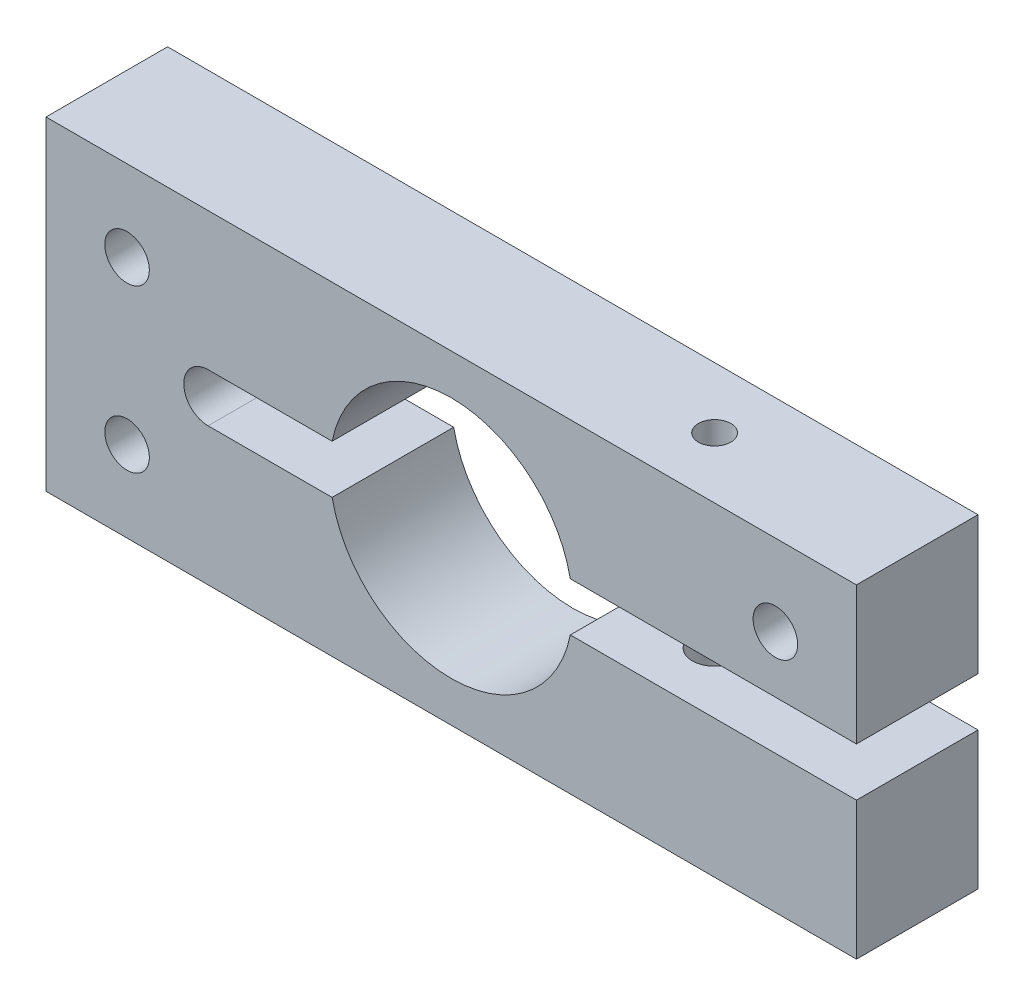
from build123d import *

# Parameters (mm, degrees)
SKETCH1_R           = 2.75
BOSS_EXTRUDE1_DEPTH = 15
SKETCH2_R           = 2
CUT_EXTRUDE1_DEPTH  = 41
SKETCH3_R           = 4.5
CUT_EXTRUDE2_DEPTH  = 5
SKETCH4_R           = 4.5
CUT_EXTRUDE3_DEPTH  = 5
CUT_EXTRUDE4_REACH  = 37
SKETCH5_R           = 2.75


with BuildPart() as part:
    # Sketch1 → Boss-Extrude1 (new body)
    with BuildSketch(Plane.XY):
        with BuildLine():
            Line((0, 0), (100, 0))
            Line((100, 0), (100, 17))
            Line((100, 17), (64.696938457, 17))
            ThreePointArc((64.696938457, 17), (50, 5), (35.303061543, 17))
            Line((35.303061543, 17), (20, 17))
            ThreePointArc((20, 17), (17, 20), (20, 23))
            Line((20, 23), (35.303061543, 23))
            ThreePointArc((35.303061543, 23), (50, 35), (64.696938457, 23))
            Line((64.696938457, 23), (100, 23))
            Line((100, 23), (100, 40))
            Line((100, 40), (0, 40))
            Line((0, 40), (0, 0))
        make_face()
        with Locations((10, 30)):
            Circle(SKETCH1_R, mode=Mode.SUBTRACT)
        with Locations((10, 10)):
            Circle(SKETCH1_R, mode=Mode.SUBTRACT)
        with Locations((90, 30)):
            Circle(SKETCH1_R, mode=Mode.SUBTRACT)
    extrude(amount=BOSS_EXTRUDE1_DEPTH)

    # Sketch2 → Cut-Extrude1 (cut, through all)
    with BuildSketch(Plane.XZ):
        with Locations((75, 7.5)):
            Circle(SKETCH2_R)
    extrude(amount=-CUT_EXTRUDE1_DEPTH, mode=Mode.SUBTRACT)

    # Sketch3 → Cut-Extrude2 (cut)
    with BuildSketch(Plane.XZ):
        with Locations((75, 7.5)):
            Circle(SKETCH3_R)
    extrude(amount=-CUT_EXTRUDE2_DEPTH, mode=Mode.SUBTRACT)

    # Sketch4 → Cut-Extrude3 (cut)
    with BuildSketch(Plane.XY):
        with Locations((10, 10)):
            Circle(SKETCH4_R)
        with Locations((10, 30)):
            Circle(SKETCH4_R)
        with Locations((90, 30)):
            Circle(SKETCH4_R)
    extrude(amount=CUT_EXTRUDE3_DEPTH, mode=Mode.SUBTRACT)

    # Sketch5 → Cut-Extrude4 (cut, up to next)
    with BuildSketch(Plane.XZ.offset(-5), mode=Mode.PRIVATE) as cut_extrude4_sk1:
        with Locations((75, 7.5)):
            Circle(SKETCH5_R)
    cut_extrude4_tool1 = extrude(cut_extrude4_sk1.sketch, amount=-CUT_EXTRUDE4_REACH, mode=Mode.PRIVATE) & part.part
    add(cut_extrude4_tool1.solids().sort_by_distance((75, 5, 7.5))[0], mode=Mode.SUBTRACT)


solid = part.part
